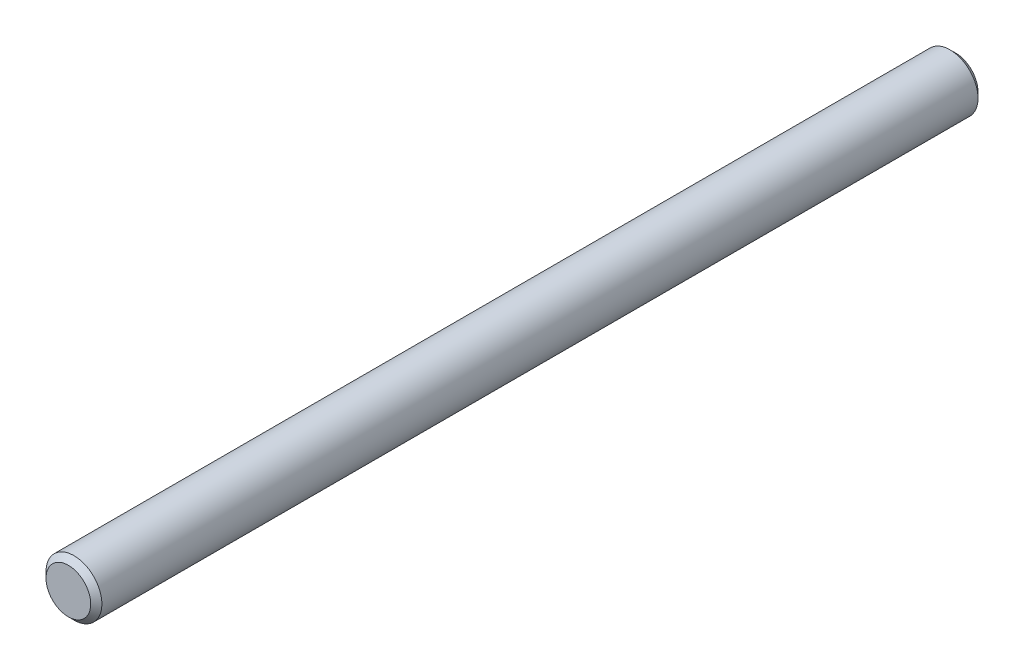
from build123d import *

# Parameters (mm, degrees)
SKETCH1_R      = 4.7625
EXTRUDE1_DEPTH = 75.6
CHAMFER1_SIZE  = 0.9525


with BuildPart() as part:
    # Sketch1 → Extrude1 (new body, symmetric)
    with BuildSketch(Plane.XY):
        Circle(SKETCH1_R)
    extrude(amount=EXTRUDE1_DEPTH, both=True)

    # Chamfer1
    chamfer1_edges = [part.edges().sort_by_distance(p)[0] for p in [
        (-4.7625, 0, -75.6),
        (-4.7625, 0, 75.6),
    ]]
    chamfer(chamfer1_edges, length=CHAMFER1_SIZE)


solid = part.part
